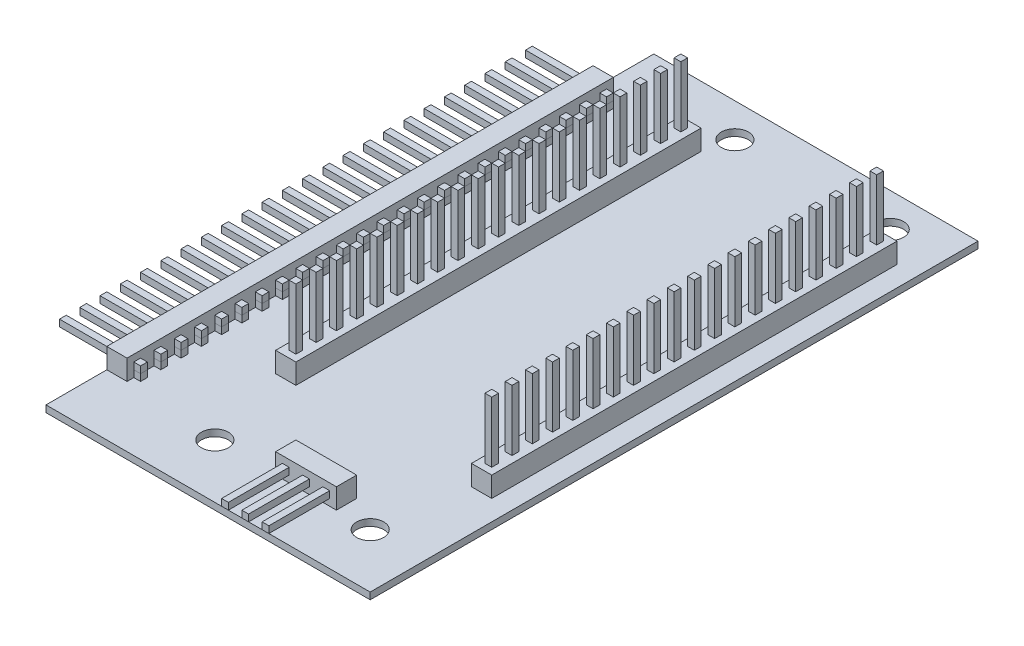
from build123d import *

# Parameters (mm, degrees)
SKETCH1_W              = 38.1
SKETCH1_H              = 71.4375
BOSS_EXTRUDE1_DEPTH    = 0.79375
SKETCH2_W              = 0.79375
SKETCH2_H              = 0.79375
BOSS_EXTRUDE2_DEPTH    = 0.79375
BOSS_EXTRUDE2_2_DEPTH  = 0.79375
BOSS_EXTRUDE2_3_DEPTH  = 0.79375
BOSS_EXTRUDE2_4_DEPTH  = 0.79375
BOSS_EXTRUDE2_5_DEPTH  = 0.79375
BOSS_EXTRUDE2_6_DEPTH  = 0.79375
BOSS_EXTRUDE2_7_DEPTH  = 0.79375
BOSS_EXTRUDE2_8_DEPTH  = 0.79375
BOSS_EXTRUDE2_9_DEPTH  = 0.79375
BOSS_EXTRUDE2_10_DEPTH = 0.79375
BOSS_EXTRUDE2_11_DEPTH = 0.79375
BOSS_EXTRUDE2_12_DEPTH = 0.79375
BOSS_EXTRUDE2_13_DEPTH = 0.79375
BOSS_EXTRUDE2_14_DEPTH = 0.79375
BOSS_EXTRUDE2_15_DEPTH = 0.79375
BOSS_EXTRUDE2_16_DEPTH = 0.79375
BOSS_EXTRUDE2_17_DEPTH = 0.79375
BOSS_EXTRUDE2_18_DEPTH = 0.79375
BOSS_EXTRUDE2_19_DEPTH = 0.79375
BOSS_EXTRUDE2_20_DEPTH = 0.79375
BOSS_EXTRUDE2_21_DEPTH = 0.79375
BOSS_EXTRUDE2_22_DEPTH = 0.79375
BOSS_EXTRUDE2_23_DEPTH = 0.79375
BOSS_EXTRUDE2_24_DEPTH = 0.79375
BOSS_EXTRUDE3_START    = 0.79375
SKETCH2_3_W            = 9.525
SKETCH2_3_H            = 0.79375
BOSS_EXTRUDE3_DEPTH    = 0.79375
BOSS_EXTRUDE3_2_DEPTH  = 0.79375
BOSS_EXTRUDE3_3_DEPTH  = 0.79375
BOSS_EXTRUDE3_4_DEPTH  = 0.79375
BOSS_EXTRUDE3_5_DEPTH  = 0.79375
BOSS_EXTRUDE3_6_DEPTH  = 0.79375
BOSS_EXTRUDE3_7_DEPTH  = 0.79375
BOSS_EXTRUDE3_8_DEPTH  = 0.79375
BOSS_EXTRUDE3_9_DEPTH  = 0.79375
BOSS_EXTRUDE3_10_DEPTH = 0.79375
BOSS_EXTRUDE3_11_DEPTH = 0.79375
BOSS_EXTRUDE3_12_DEPTH = 0.79375
BOSS_EXTRUDE3_13_DEPTH = 0.79375
BOSS_EXTRUDE3_14_DEPTH = 0.79375
BOSS_EXTRUDE3_15_DEPTH = 0.79375
BOSS_EXTRUDE3_16_DEPTH = 0.79375
BOSS_EXTRUDE3_17_DEPTH = 0.79375
BOSS_EXTRUDE3_18_DEPTH = 0.79375
BOSS_EXTRUDE3_19_DEPTH = 0.79375
BOSS_EXTRUDE3_20_DEPTH = 0.79375
BOSS_EXTRUDE3_21_DEPTH = 0.79375
BOSS_EXTRUDE3_22_DEPTH = 0.79375
BOSS_EXTRUDE3_23_DEPTH = 0.79375
BOSS_EXTRUDE3_24_DEPTH = 0.79375
SKETCH3_W              = 2.38125
SKETCH3_H              = 57.15
BOSS_EXTRUDE4_DEPTH    = 2.38125
SKETCH4_W              = 0.79375
SKETCH4_H              = 0.79375
BOSS_EXTRUDE5_DEPTH    = 9.525
BOSS_EXTRUDE5_2_DEPTH  = 9.525
BOSS_EXTRUDE5_3_DEPTH  = 9.525
BOSS_EXTRUDE5_4_DEPTH  = 9.525
BOSS_EXTRUDE5_5_DEPTH  = 9.525
BOSS_EXTRUDE5_6_DEPTH  = 9.525
BOSS_EXTRUDE5_7_DEPTH  = 9.525
BOSS_EXTRUDE5_8_DEPTH  = 9.525
BOSS_EXTRUDE5_9_DEPTH  = 9.525
BOSS_EXTRUDE5_10_DEPTH = 9.525
BOSS_EXTRUDE5_11_DEPTH = 9.525
BOSS_EXTRUDE5_12_DEPTH = 9.525
BOSS_EXTRUDE5_13_DEPTH = 9.525
BOSS_EXTRUDE5_14_DEPTH = 9.525
BOSS_EXTRUDE5_15_DEPTH = 9.525
BOSS_EXTRUDE5_16_DEPTH = 9.525
BOSS_EXTRUDE5_17_DEPTH = 9.525
BOSS_EXTRUDE5_18_DEPTH = 9.525
BOSS_EXTRUDE5_19_DEPTH = 9.525
BOSS_EXTRUDE5_20_DEPTH = 9.525
BOSS_EXTRUDE5_21_DEPTH = 9.525
BOSS_EXTRUDE5_22_DEPTH = 9.525
BOSS_EXTRUDE5_23_DEPTH = 9.525
BOSS_EXTRUDE5_24_DEPTH = 9.525
BOSS_EXTRUDE5_25_DEPTH = 9.525
BOSS_EXTRUDE5_26_DEPTH = 9.525
BOSS_EXTRUDE5_27_DEPTH = 9.525
BOSS_EXTRUDE5_28_DEPTH = 9.525
BOSS_EXTRUDE5_29_DEPTH = 9.525
BOSS_EXTRUDE5_30_DEPTH = 9.525
BOSS_EXTRUDE5_31_DEPTH = 9.525
BOSS_EXTRUDE5_32_DEPTH = 9.525
BOSS_EXTRUDE5_33_DEPTH = 9.525
BOSS_EXTRUDE5_34_DEPTH = 9.525
BOSS_EXTRUDE5_35_DEPTH = 9.525
BOSS_EXTRUDE5_36_DEPTH = 9.525
BOSS_EXTRUDE5_37_DEPTH = 9.525
BOSS_EXTRUDE5_38_DEPTH = 9.525
BOSS_EXTRUDE5_39_DEPTH = 9.525
BOSS_EXTRUDE5_40_DEPTH = 9.525
SKETCH5_W              = 2.38125
SKETCH5_H              = 47.625
BOSS_EXTRUDE6_DEPTH    = 2.38125
SKETCH6_W              = 0.79375
SKETCH6_H              = 0.79375
BOSS_EXTRUDE7_DEPTH    = 0.79375
BOSS_EXTRUDE8_START    = 0.79375
SKETCH6_3_W            = 0.79375
SKETCH6_3_H            = 10.31875
BOSS_EXTRUDE8_DEPTH    = 0.79375
BOSS_EXTRUDE8_2_DEPTH  = 0.79375
BOSS_EXTRUDE8_3_DEPTH  = 0.79375
SKETCH7_W              = 7.14375
SKETCH7_H              = 2.38125
BOSS_EXTRUDE9_DEPTH    = 2.38125
SKETCH8_R              = 1.5875
CUT_EXTRUDE1_DEPTH     = 46.486792383


with BuildPart() as part:
    # Sketch1 → Boss-Extrude1 (new body)
    with BuildSketch(Plane(origin=(0, 0, 0), x_dir=(1, 0, 0), z_dir=(0, 1, 0))):
        Rectangle(SKETCH1_W, SKETCH1_H)
    extrude(amount=BOSS_EXTRUDE1_DEPTH)

    # Sketch5 → Boss-Extrude6 (add)
    with BuildSketch(Plane(origin=(0, 0.79375, 0), x_dir=(1, 0, 0), z_dir=(0, 1, 0))):
        with Locations((-7.540625, 4.7625)):
            Rectangle(SKETCH5_W, SKETCH5_H)
        with Locations((15.478125, 4.7625)):
            Rectangle(SKETCH5_W, SKETCH5_H)
    extrude(amount=BOSS_EXTRUDE6_DEPTH)

    # Sketch6 → Boss-Extrude7 (add)
    with BuildSketch(Plane(origin=(0, 0.79375, 0), x_dir=(1, 0, 0), z_dir=(0, 1, 0))):
        with Locations((2.778125, -26.590625)):
            Rectangle(SKETCH6_W, SKETCH6_H)
        with Locations((5.159375, -26.590625)):
            Rectangle(SKETCH6_W, SKETCH6_H)
        with Locations((7.540625, -26.590625)):
            Rectangle(SKETCH6_W, SKETCH6_H)
    extrude(amount=BOSS_EXTRUDE7_DEPTH)

    # Sketch7 → Boss-Extrude9 (add)
    with BuildSketch(Plane(origin=(0, 0.79375, 0), x_dir=(1, 0, 0), z_dir=(0, 1, 0))):
        with Locations((5.159375, -28.178125)):
            Rectangle(SKETCH7_W, SKETCH7_H)
    extrude(amount=BOSS_EXTRUDE9_DEPTH)

    # Sketch8 → Cut-Extrude1 (cut, through all)
    with BuildSketch(Plane(origin=(0, 0.79375, 0), x_dir=(1, 0, 0), z_dir=(0, 1, 0))):
        with Locations((-5.55625, 31.75)):
            Circle(SKETCH8_R)
        with Locations((12.7, 31.75)):
            Circle(SKETCH8_R)
        with Locations((-5.55625, -29.36875)):
            Circle(SKETCH8_R)
        with Locations((12.7, -29.36875)):
            Circle(SKETCH8_R)
    extrude(amount=-CUT_EXTRUDE1_DEPTH, mode=Mode.SUBTRACT)


with BuildPart() as body_2:
    # Sketch2 → Boss-Extrude2 (new body)
    with BuildSketch(Plane(origin=(0, 0.79375, 0), x_dir=(1, 0, 0), z_dir=(0, 1, 0))):
        with Locations((-16.271875, 1.190625)):
            Rectangle(SKETCH2_W, SKETCH2_H)
    extrude(amount=BOSS_EXTRUDE2_DEPTH)


with BuildPart() as body_3:
    # Sketch2 → Boss-Extrude2 2 (new body)
    with BuildSketch(Plane(origin=(0, 0.79375, 0), x_dir=(1, 0, 0), z_dir=(0, 1, 0))):
        with Locations((-16.271875, 3.571875)):
            Rectangle(SKETCH2_W, SKETCH2_H)
    extrude(amount=BOSS_EXTRUDE2_2_DEPTH)


with BuildPart() as body_4:
    # Sketch2 → Boss-Extrude2 3 (new body)
    with BuildSketch(Plane(origin=(0, 0.79375, 0), x_dir=(1, 0, 0), z_dir=(0, 1, 0))):
        with Locations((-16.271875, 8.334375)):
            Rectangle(SKETCH2_W, SKETCH2_H)
    extrude(amount=BOSS_EXTRUDE2_3_DEPTH)


with BuildPart() as body_5:
    # Sketch2 → Boss-Extrude2 4 (new body)
    with BuildSketch(Plane(origin=(0, 0.79375, 0), x_dir=(1, 0, 0), z_dir=(0, 1, 0))):
        with Locations((-16.271875, 5.953125)):
            Rectangle(SKETCH2_W, SKETCH2_H)
    extrude(amount=BOSS_EXTRUDE2_4_DEPTH)


with BuildPart() as body_6:
    # Sketch2 → Boss-Extrude2 5 (new body)
    with BuildSketch(Plane(origin=(0, 0.79375, 0), x_dir=(1, 0, 0), z_dir=(0, 1, 0))):
        with Locations((-16.271875, 10.715625)):
            Rectangle(SKETCH2_W, SKETCH2_H)
    extrude(amount=BOSS_EXTRUDE2_5_DEPTH)


with BuildPart() as body_7:
    # Sketch2 → Boss-Extrude2 6 (new body)
    with BuildSketch(Plane(origin=(0, 0.79375, 0), x_dir=(1, 0, 0), z_dir=(0, 1, 0))):
        with Locations((-16.271875, 13.096875)):
            Rectangle(SKETCH2_W, SKETCH2_H)
    extrude(amount=BOSS_EXTRUDE2_6_DEPTH)


with BuildPart() as body_8:
    # Sketch2 → Boss-Extrude2 7 (new body)
    with BuildSketch(Plane(origin=(0, 0.79375, 0), x_dir=(1, 0, 0), z_dir=(0, 1, 0))):
        with Locations((-16.271875, 15.478125)):
            Rectangle(SKETCH2_W, SKETCH2_H)
    extrude(amount=BOSS_EXTRUDE2_7_DEPTH)


with BuildPart() as body_9:
    # Sketch2 → Boss-Extrude2 8 (new body)
    with BuildSketch(Plane(origin=(0, 0.79375, 0), x_dir=(1, 0, 0), z_dir=(0, 1, 0))):
        with Locations((-16.271875, 17.859375)):
            Rectangle(SKETCH2_W, SKETCH2_H)
    extrude(amount=BOSS_EXTRUDE2_8_DEPTH)


with BuildPart() as body_10:
    # Sketch2 → Boss-Extrude2 9 (new body)
    with BuildSketch(Plane(origin=(0, 0.79375, 0), x_dir=(1, 0, 0), z_dir=(0, 1, 0))):
        with Locations((-16.271875, 20.240625)):
            Rectangle(SKETCH2_W, SKETCH2_H)
    extrude(amount=BOSS_EXTRUDE2_9_DEPTH)


with BuildPart() as body_11:
    # Sketch2 → Boss-Extrude2 10 (new body)
    with BuildSketch(Plane(origin=(0, 0.79375, 0), x_dir=(1, 0, 0), z_dir=(0, 1, 0))):
        with Locations((-16.271875, 22.621875)):
            Rectangle(SKETCH2_W, SKETCH2_H)
    extrude(amount=BOSS_EXTRUDE2_10_DEPTH)


with BuildPart() as body_12:
    # Sketch2 → Boss-Extrude2 11 (new body)
    with BuildSketch(Plane(origin=(0, 0.79375, 0), x_dir=(1, 0, 0), z_dir=(0, 1, 0))):
        with Locations((-16.271875, 25.003125)):
            Rectangle(SKETCH2_W, SKETCH2_H)
    extrude(amount=BOSS_EXTRUDE2_11_DEPTH)


with BuildPart() as body_13:
    # Sketch2 → Boss-Extrude2 12 (new body)
    with BuildSketch(Plane(origin=(0, 0.79375, 0), x_dir=(1, 0, 0), z_dir=(0, 1, 0))):
        with Locations((-16.271875, 27.384375)):
            Rectangle(SKETCH2_W, SKETCH2_H)
    extrude(amount=BOSS_EXTRUDE2_12_DEPTH)


with BuildPart() as body_14:
    # Sketch2 → Boss-Extrude2 13 (new body)
    with BuildSketch(Plane(origin=(0, 0.79375, 0), x_dir=(1, 0, 0), z_dir=(0, 1, 0))):
        with Locations((-16.271875, -27.384375)):
            Rectangle(SKETCH2_W, SKETCH2_H)
    extrude(amount=BOSS_EXTRUDE2_13_DEPTH)


with BuildPart() as body_15:
    # Sketch2 → Boss-Extrude2 14 (new body)
    with BuildSketch(Plane(origin=(0, 0.79375, 0), x_dir=(1, 0, 0), z_dir=(0, 1, 0))):
        with Locations((-16.271875, -25.003125)):
            Rectangle(SKETCH2_W, SKETCH2_H)
    extrude(amount=BOSS_EXTRUDE2_14_DEPTH)


with BuildPart() as body_16:
    # Sketch2 → Boss-Extrude2 15 (new body)
    with BuildSketch(Plane(origin=(0, 0.79375, 0), x_dir=(1, 0, 0), z_dir=(0, 1, 0))):
        with Locations((-16.271875, -22.621875)):
            Rectangle(SKETCH2_W, SKETCH2_H)
    extrude(amount=BOSS_EXTRUDE2_15_DEPTH)


with BuildPart() as body_17:
    # Sketch2 → Boss-Extrude2 16 (new body)
    with BuildSketch(Plane(origin=(0, 0.79375, 0), x_dir=(1, 0, 0), z_dir=(0, 1, 0))):
        with Locations((-16.271875, -17.859375)):
            Rectangle(SKETCH2_W, SKETCH2_H)
    extrude(amount=BOSS_EXTRUDE2_16_DEPTH)


with BuildPart() as body_18:
    # Sketch2 → Boss-Extrude2 17 (new body)
    with BuildSketch(Plane(origin=(0, 0.79375, 0), x_dir=(1, 0, 0), z_dir=(0, 1, 0))):
        with Locations((-16.271875, -20.240625)):
            Rectangle(SKETCH2_W, SKETCH2_H)
    extrude(amount=BOSS_EXTRUDE2_17_DEPTH)


with BuildPart() as body_19:
    # Sketch2 → Boss-Extrude2 18 (new body)
    with BuildSketch(Plane(origin=(0, 0.79375, 0), x_dir=(1, 0, 0), z_dir=(0, 1, 0))):
        with Locations((-16.271875, -15.478125)):
            Rectangle(SKETCH2_W, SKETCH2_H)
    extrude(amount=BOSS_EXTRUDE2_18_DEPTH)


with BuildPart() as body_20:
    # Sketch2 → Boss-Extrude2 19 (new body)
    with BuildSketch(Plane(origin=(0, 0.79375, 0), x_dir=(1, 0, 0), z_dir=(0, 1, 0))):
        with Locations((-16.271875, -13.096875)):
            Rectangle(SKETCH2_W, SKETCH2_H)
    extrude(amount=BOSS_EXTRUDE2_19_DEPTH)


with BuildPart() as body_21:
    # Sketch2 → Boss-Extrude2 20 (new body)
    with BuildSketch(Plane(origin=(0, 0.79375, 0), x_dir=(1, 0, 0), z_dir=(0, 1, 0))):
        with Locations((-16.271875, -10.715625)):
            Rectangle(SKETCH2_W, SKETCH2_H)
    extrude(amount=BOSS_EXTRUDE2_20_DEPTH)


with BuildPart() as body_22:
    # Sketch2 → Boss-Extrude2 21 (new body)
    with BuildSketch(Plane(origin=(0, 0.79375, 0), x_dir=(1, 0, 0), z_dir=(0, 1, 0))):
        with Locations((-16.271875, -5.953125)):
            Rectangle(SKETCH2_W, SKETCH2_H)
    extrude(amount=BOSS_EXTRUDE2_21_DEPTH)


with BuildPart() as body_23:
    # Sketch2 → Boss-Extrude2 22 (new body)
    with BuildSketch(Plane(origin=(0, 0.79375, 0), x_dir=(1, 0, 0), z_dir=(0, 1, 0))):
        with Locations((-16.271875, -8.334375)):
            Rectangle(SKETCH2_W, SKETCH2_H)
    extrude(amount=BOSS_EXTRUDE2_22_DEPTH)


with BuildPart() as body_24:
    # Sketch2 → Boss-Extrude2 23 (new body)
    with BuildSketch(Plane(origin=(0, 0.79375, 0), x_dir=(1, 0, 0), z_dir=(0, 1, 0))):
        with Locations((-16.271875, -3.571875)):
            Rectangle(SKETCH2_W, SKETCH2_H)
    extrude(amount=BOSS_EXTRUDE2_23_DEPTH)


with BuildPart() as body_25:
    # Sketch2 → Boss-Extrude2 24 (new body)
    with BuildSketch(Plane(origin=(0, 0.79375, 0), x_dir=(1, 0, 0), z_dir=(0, 1, 0))):
        with Locations((-16.271875, -1.190625)):
            Rectangle(SKETCH2_W, SKETCH2_H)
    extrude(amount=BOSS_EXTRUDE2_24_DEPTH)


with BuildPart() as body_26:
    # Sketch2_3 → Boss-Extrude3 (new body)
    with BuildSketch(Plane(origin=(0, 0.79375, 0), x_dir=(1, 0, 0), z_dir=(0, 1, 0)).offset(BOSS_EXTRUDE3_START)):
        with Locations((-20.6375, 1.190625)):
            Rectangle(SKETCH2_3_W, SKETCH2_3_H)
    extrude(amount=BOSS_EXTRUDE3_DEPTH)


with BuildPart() as body_27:
    # Sketch2_3 → Boss-Extrude3 2 (new body)
    with BuildSketch(Plane(origin=(0, 0.79375, 0), x_dir=(1, 0, 0), z_dir=(0, 1, 0)).offset(BOSS_EXTRUDE3_START)):
        with Locations((-20.6375, 3.571875)):
            Rectangle(SKETCH2_3_W, SKETCH2_3_H)
    extrude(amount=BOSS_EXTRUDE3_2_DEPTH)


with BuildPart() as body_28:
    # Sketch2_3 → Boss-Extrude3 3 (new body)
    with BuildSketch(Plane(origin=(0, 0.79375, 0), x_dir=(1, 0, 0), z_dir=(0, 1, 0)).offset(BOSS_EXTRUDE3_START)):
        with Locations((-20.6375, 8.334375)):
            Rectangle(SKETCH2_3_W, SKETCH2_3_H)
    extrude(amount=BOSS_EXTRUDE3_3_DEPTH)


with BuildPart() as body_29:
    # Sketch2_3 → Boss-Extrude3 4 (new body)
    with BuildSketch(Plane(origin=(0, 0.79375, 0), x_dir=(1, 0, 0), z_dir=(0, 1, 0)).offset(BOSS_EXTRUDE3_START)):
        with Locations((-20.6375, 5.953125)):
            Rectangle(SKETCH2_3_W, SKETCH2_3_H)
    extrude(amount=BOSS_EXTRUDE3_4_DEPTH)


with BuildPart() as body_30:
    # Sketch2_3 → Boss-Extrude3 5 (new body)
    with BuildSketch(Plane(origin=(0, 0.79375, 0), x_dir=(1, 0, 0), z_dir=(0, 1, 0)).offset(BOSS_EXTRUDE3_START)):
        with Locations((-20.6375, 10.715625)):
            Rectangle(SKETCH2_3_W, SKETCH2_3_H)
    extrude(amount=BOSS_EXTRUDE3_5_DEPTH)


with BuildPart() as body_31:
    # Sketch2_3 → Boss-Extrude3 6 (new body)
    with BuildSketch(Plane(origin=(0, 0.79375, 0), x_dir=(1, 0, 0), z_dir=(0, 1, 0)).offset(BOSS_EXTRUDE3_START)):
        with Locations((-20.6375, 13.096875)):
            Rectangle(SKETCH2_3_W, SKETCH2_3_H)
    extrude(amount=BOSS_EXTRUDE3_6_DEPTH)


with BuildPart() as body_32:
    # Sketch2_3 → Boss-Extrude3 7 (new body)
    with BuildSketch(Plane(origin=(0, 0.79375, 0), x_dir=(1, 0, 0), z_dir=(0, 1, 0)).offset(BOSS_EXTRUDE3_START)):
        with Locations((-20.6375, 15.478125)):
            Rectangle(SKETCH2_3_W, SKETCH2_3_H)
    extrude(amount=BOSS_EXTRUDE3_7_DEPTH)


with BuildPart() as body_33:
    # Sketch2_3 → Boss-Extrude3 8 (new body)
    with BuildSketch(Plane(origin=(0, 0.79375, 0), x_dir=(1, 0, 0), z_dir=(0, 1, 0)).offset(BOSS_EXTRUDE3_START)):
        with Locations((-20.6375, 17.859375)):
            Rectangle(SKETCH2_3_W, SKETCH2_3_H)
    extrude(amount=BOSS_EXTRUDE3_8_DEPTH)


with BuildPart() as body_34:
    # Sketch2_3 → Boss-Extrude3 9 (new body)
    with BuildSketch(Plane(origin=(0, 0.79375, 0), x_dir=(1, 0, 0), z_dir=(0, 1, 0)).offset(BOSS_EXTRUDE3_START)):
        with Locations((-20.6375, 20.240625)):
            Rectangle(SKETCH2_3_W, SKETCH2_3_H)
    extrude(amount=BOSS_EXTRUDE3_9_DEPTH)


with BuildPart() as body_35:
    # Sketch2_3 → Boss-Extrude3 10 (new body)
    with BuildSketch(Plane(origin=(0, 0.79375, 0), x_dir=(1, 0, 0), z_dir=(0, 1, 0)).offset(BOSS_EXTRUDE3_START)):
        with Locations((-20.6375, 22.621875)):
            Rectangle(SKETCH2_3_W, SKETCH2_3_H)
    extrude(amount=BOSS_EXTRUDE3_10_DEPTH)


with BuildPart() as body_36:
    # Sketch2_3 → Boss-Extrude3 11 (new body)
    with BuildSketch(Plane(origin=(0, 0.79375, 0), x_dir=(1, 0, 0), z_dir=(0, 1, 0)).offset(BOSS_EXTRUDE3_START)):
        with Locations((-20.6375, 25.003125)):
            Rectangle(SKETCH2_3_W, SKETCH2_3_H)
    extrude(amount=BOSS_EXTRUDE3_11_DEPTH)


with BuildPart() as body_37:
    # Sketch2_3 → Boss-Extrude3 12 (new body)
    with BuildSketch(Plane(origin=(0, 0.79375, 0), x_dir=(1, 0, 0), z_dir=(0, 1, 0)).offset(BOSS_EXTRUDE3_START)):
        with Locations((-20.6375, 27.384375)):
            Rectangle(SKETCH2_3_W, SKETCH2_3_H)
    extrude(amount=BOSS_EXTRUDE3_12_DEPTH)


with BuildPart() as body_38:
    # Sketch2_3 → Boss-Extrude3 13 (new body)
    with BuildSketch(Plane(origin=(0, 0.79375, 0), x_dir=(1, 0, 0), z_dir=(0, 1, 0)).offset(BOSS_EXTRUDE3_START)):
        with Locations((-20.6375, -27.384375)):
            Rectangle(SKETCH2_3_W, SKETCH2_3_H)
    extrude(amount=BOSS_EXTRUDE3_13_DEPTH)


with BuildPart() as body_39:
    # Sketch2_3 → Boss-Extrude3 14 (new body)
    with BuildSketch(Plane(origin=(0, 0.79375, 0), x_dir=(1, 0, 0), z_dir=(0, 1, 0)).offset(BOSS_EXTRUDE3_START)):
        with Locations((-20.6375, -25.003125)):
            Rectangle(SKETCH2_3_W, SKETCH2_3_H)
    extrude(amount=BOSS_EXTRUDE3_14_DEPTH)


with BuildPart() as body_40:
    # Sketch2_3 → Boss-Extrude3 15 (new body)
    with BuildSketch(Plane(origin=(0, 0.79375, 0), x_dir=(1, 0, 0), z_dir=(0, 1, 0)).offset(BOSS_EXTRUDE3_START)):
        with Locations((-20.6375, -22.621875)):
            Rectangle(SKETCH2_3_W, SKETCH2_3_H)
    extrude(amount=BOSS_EXTRUDE3_15_DEPTH)


with BuildPart() as body_41:
    # Sketch2_3 → Boss-Extrude3 16 (new body)
    with BuildSketch(Plane(origin=(0, 0.79375, 0), x_dir=(1, 0, 0), z_dir=(0, 1, 0)).offset(BOSS_EXTRUDE3_START)):
        with Locations((-20.6375, -20.240625)):
            Rectangle(SKETCH2_3_W, SKETCH2_3_H)
    extrude(amount=BOSS_EXTRUDE3_16_DEPTH)


with BuildPart() as body_42:
    # Sketch2_3 → Boss-Extrude3 17 (new body)
    with BuildSketch(Plane(origin=(0, 0.79375, 0), x_dir=(1, 0, 0), z_dir=(0, 1, 0)).offset(BOSS_EXTRUDE3_START)):
        with Locations((-20.6375, -17.859375)):
            Rectangle(SKETCH2_3_W, SKETCH2_3_H)
    extrude(amount=BOSS_EXTRUDE3_17_DEPTH)


with BuildPart() as body_43:
    # Sketch2_3 → Boss-Extrude3 18 (new body)
    with BuildSketch(Plane(origin=(0, 0.79375, 0), x_dir=(1, 0, 0), z_dir=(0, 1, 0)).offset(BOSS_EXTRUDE3_START)):
        with Locations((-20.6375, -15.478125)):
            Rectangle(SKETCH2_3_W, SKETCH2_3_H)
    extrude(amount=BOSS_EXTRUDE3_18_DEPTH)


with BuildPart() as body_44:
    # Sketch2_3 → Boss-Extrude3 19 (new body)
    with BuildSketch(Plane(origin=(0, 0.79375, 0), x_dir=(1, 0, 0), z_dir=(0, 1, 0)).offset(BOSS_EXTRUDE3_START)):
        with Locations((-20.6375, -13.096875)):
            Rectangle(SKETCH2_3_W, SKETCH2_3_H)
    extrude(amount=BOSS_EXTRUDE3_19_DEPTH)


with BuildPart() as body_45:
    # Sketch2_3 → Boss-Extrude3 20 (new body)
    with BuildSketch(Plane(origin=(0, 0.79375, 0), x_dir=(1, 0, 0), z_dir=(0, 1, 0)).offset(BOSS_EXTRUDE3_START)):
        with Locations((-20.6375, -10.715625)):
            Rectangle(SKETCH2_3_W, SKETCH2_3_H)
    extrude(amount=BOSS_EXTRUDE3_20_DEPTH)


with BuildPart() as body_46:
    # Sketch2_3 → Boss-Extrude3 21 (new body)
    with BuildSketch(Plane(origin=(0, 0.79375, 0), x_dir=(1, 0, 0), z_dir=(0, 1, 0)).offset(BOSS_EXTRUDE3_START)):
        with Locations((-20.6375, -5.953125)):
            Rectangle(SKETCH2_3_W, SKETCH2_3_H)
    extrude(amount=BOSS_EXTRUDE3_21_DEPTH)


with BuildPart() as body_47:
    # Sketch2_3 → Boss-Extrude3 22 (new body)
    with BuildSketch(Plane(origin=(0, 0.79375, 0), x_dir=(1, 0, 0), z_dir=(0, 1, 0)).offset(BOSS_EXTRUDE3_START)):
        with Locations((-20.6375, -8.334375)):
            Rectangle(SKETCH2_3_W, SKETCH2_3_H)
    extrude(amount=BOSS_EXTRUDE3_22_DEPTH)


with BuildPart() as body_48:
    # Sketch2_3 → Boss-Extrude3 23 (new body)
    with BuildSketch(Plane(origin=(0, 0.79375, 0), x_dir=(1, 0, 0), z_dir=(0, 1, 0)).offset(BOSS_EXTRUDE3_START)):
        with Locations((-20.6375, -3.571875)):
            Rectangle(SKETCH2_3_W, SKETCH2_3_H)
    extrude(amount=BOSS_EXTRUDE3_23_DEPTH)


with BuildPart() as body_49:
    # Sketch2_3 → Boss-Extrude3 24 (new body)
    with BuildSketch(Plane(origin=(0, 0.79375, 0), x_dir=(1, 0, 0), z_dir=(0, 1, 0)).offset(BOSS_EXTRUDE3_START)):
        with Locations((-20.6375, -1.190625)):
            Rectangle(SKETCH2_3_W, SKETCH2_3_H)
    extrude(amount=BOSS_EXTRUDE3_24_DEPTH)


with BuildPart() as body_50:
    # Sketch3 → Boss-Extrude4 (new body)
    with BuildSketch(Plane(origin=(0, 0.79375, 0), x_dir=(1, 0, 0), z_dir=(0, 1, 0))):
        with Locations((-17.859375, 0)):
            Rectangle(SKETCH3_W, SKETCH3_H)
    extrude(amount=BOSS_EXTRUDE4_DEPTH)


with BuildPart() as body_51:
    # Sketch4 → Boss-Extrude5 (new body)
    with BuildSketch(Plane(origin=(0, 0.79375, 0), x_dir=(1, 0, 0), z_dir=(0, 1, 0))):
        with Locations((-7.540625, 25.003125)):
            Rectangle(SKETCH4_W, SKETCH4_H)
    extrude(amount=BOSS_EXTRUDE5_DEPTH)


with BuildPart() as body_52:
    # Sketch4 → Boss-Extrude5 2 (new body)
    with BuildSketch(Plane(origin=(0, 0.79375, 0), x_dir=(1, 0, 0), z_dir=(0, 1, 0))):
        with Locations((-7.540625, 22.621875)):
            Rectangle(SKETCH4_W, SKETCH4_H)
    extrude(amount=BOSS_EXTRUDE5_2_DEPTH)


with BuildPart() as body_53:
    # Sketch4 → Boss-Extrude5 3 (new body)
    with BuildSketch(Plane(origin=(0, 0.79375, 0), x_dir=(1, 0, 0), z_dir=(0, 1, 0))):
        with Locations((-7.540625, 20.240625)):
            Rectangle(SKETCH4_W, SKETCH4_H)
    extrude(amount=BOSS_EXTRUDE5_3_DEPTH)


with BuildPart() as body_54:
    # Sketch4 → Boss-Extrude5 4 (new body)
    with BuildSketch(Plane(origin=(0, 0.79375, 0), x_dir=(1, 0, 0), z_dir=(0, 1, 0))):
        with Locations((-7.540625, 17.859375)):
            Rectangle(SKETCH4_W, SKETCH4_H)
    extrude(amount=BOSS_EXTRUDE5_4_DEPTH)


with BuildPart() as body_55:
    # Sketch4 → Boss-Extrude5 5 (new body)
    with BuildSketch(Plane(origin=(0, 0.79375, 0), x_dir=(1, 0, 0), z_dir=(0, 1, 0))):
        with Locations((-7.540625, 15.478125)):
            Rectangle(SKETCH4_W, SKETCH4_H)
    extrude(amount=BOSS_EXTRUDE5_5_DEPTH)


with BuildPart() as body_56:
    # Sketch4 → Boss-Extrude5 6 (new body)
    with BuildSketch(Plane(origin=(0, 0.79375, 0), x_dir=(1, 0, 0), z_dir=(0, 1, 0))):
        with Locations((-7.540625, 13.096875)):
            Rectangle(SKETCH4_W, SKETCH4_H)
    extrude(amount=BOSS_EXTRUDE5_6_DEPTH)


with BuildPart() as body_57:
    # Sketch4 → Boss-Extrude5 7 (new body)
    with BuildSketch(Plane(origin=(0, 0.79375, 0), x_dir=(1, 0, 0), z_dir=(0, 1, 0))):
        with Locations((-7.540625, 10.715625)):
            Rectangle(SKETCH4_W, SKETCH4_H)
    extrude(amount=BOSS_EXTRUDE5_7_DEPTH)


with BuildPart() as body_58:
    # Sketch4 → Boss-Extrude5 8 (new body)
    with BuildSketch(Plane(origin=(0, 0.79375, 0), x_dir=(1, 0, 0), z_dir=(0, 1, 0))):
        with Locations((-7.540625, 8.334375)):
            Rectangle(SKETCH4_W, SKETCH4_H)
    extrude(amount=BOSS_EXTRUDE5_8_DEPTH)


with BuildPart() as body_59:
    # Sketch4 → Boss-Extrude5 9 (new body)
    with BuildSketch(Plane(origin=(0, 0.79375, 0), x_dir=(1, 0, 0), z_dir=(0, 1, 0))):
        with Locations((-7.540625, 27.384375)):
            Rectangle(SKETCH4_W, SKETCH4_H)
    extrude(amount=BOSS_EXTRUDE5_9_DEPTH)


with BuildPart() as body_60:
    # Sketch4 → Boss-Extrude5 10 (new body)
    with BuildSketch(Plane(origin=(0, 0.79375, 0), x_dir=(1, 0, 0), z_dir=(0, 1, 0))):
        with Locations((-7.540625, 5.953125)):
            Rectangle(SKETCH4_W, SKETCH4_H)
    extrude(amount=BOSS_EXTRUDE5_10_DEPTH)


with BuildPart() as body_61:
    # Sketch4 → Boss-Extrude5 11 (new body)
    with BuildSketch(Plane(origin=(0, 0.79375, 0), x_dir=(1, 0, 0), z_dir=(0, 1, 0))):
        with Locations((-7.540625, 3.571875)):
            Rectangle(SKETCH4_W, SKETCH4_H)
    extrude(amount=BOSS_EXTRUDE5_11_DEPTH)


with BuildPart() as body_62:
    # Sketch4 → Boss-Extrude5 12 (new body)
    with BuildSketch(Plane(origin=(0, 0.79375, 0), x_dir=(1, 0, 0), z_dir=(0, 1, 0))):
        with Locations((-7.540625, -17.859375)):
            Rectangle(SKETCH4_W, SKETCH4_H)
    extrude(amount=BOSS_EXTRUDE5_12_DEPTH)


with BuildPart() as body_63:
    # Sketch4 → Boss-Extrude5 13 (new body)
    with BuildSketch(Plane(origin=(0, 0.79375, 0), x_dir=(1, 0, 0), z_dir=(0, 1, 0))):
        with Locations((-7.540625, 1.190625)):
            Rectangle(SKETCH4_W, SKETCH4_H)
    extrude(amount=BOSS_EXTRUDE5_13_DEPTH)


with BuildPart() as body_64:
    # Sketch4 → Boss-Extrude5 14 (new body)
    with BuildSketch(Plane(origin=(0, 0.79375, 0), x_dir=(1, 0, 0), z_dir=(0, 1, 0))):
        with Locations((-7.540625, -1.190625)):
            Rectangle(SKETCH4_W, SKETCH4_H)
    extrude(amount=BOSS_EXTRUDE5_14_DEPTH)


with BuildPart() as body_65:
    # Sketch4 → Boss-Extrude5 15 (new body)
    with BuildSketch(Plane(origin=(0, 0.79375, 0), x_dir=(1, 0, 0), z_dir=(0, 1, 0))):
        with Locations((-7.540625, -3.571875)):
            Rectangle(SKETCH4_W, SKETCH4_H)
    extrude(amount=BOSS_EXTRUDE5_15_DEPTH)


with BuildPart() as body_66:
    # Sketch4 → Boss-Extrude5 16 (new body)
    with BuildSketch(Plane(origin=(0, 0.79375, 0), x_dir=(1, 0, 0), z_dir=(0, 1, 0))):
        with Locations((-7.540625, -5.953125)):
            Rectangle(SKETCH4_W, SKETCH4_H)
    extrude(amount=BOSS_EXTRUDE5_16_DEPTH)


with BuildPart() as body_67:
    # Sketch4 → Boss-Extrude5 17 (new body)
    with BuildSketch(Plane(origin=(0, 0.79375, 0), x_dir=(1, 0, 0), z_dir=(0, 1, 0))):
        with Locations((-7.540625, -8.334375)):
            Rectangle(SKETCH4_W, SKETCH4_H)
    extrude(amount=BOSS_EXTRUDE5_17_DEPTH)


with BuildPart() as body_68:
    # Sketch4 → Boss-Extrude5 18 (new body)
    with BuildSketch(Plane(origin=(0, 0.79375, 0), x_dir=(1, 0, 0), z_dir=(0, 1, 0))):
        with Locations((-7.540625, -10.715625)):
            Rectangle(SKETCH4_W, SKETCH4_H)
    extrude(amount=BOSS_EXTRUDE5_18_DEPTH)


with BuildPart() as body_69:
    # Sketch4 → Boss-Extrude5 19 (new body)
    with BuildSketch(Plane(origin=(0, 0.79375, 0), x_dir=(1, 0, 0), z_dir=(0, 1, 0))):
        with Locations((-7.540625, -13.096875)):
            Rectangle(SKETCH4_W, SKETCH4_H)
    extrude(amount=BOSS_EXTRUDE5_19_DEPTH)


with BuildPart() as body_70:
    # Sketch4 → Boss-Extrude5 20 (new body)
    with BuildSketch(Plane(origin=(0, 0.79375, 0), x_dir=(1, 0, 0), z_dir=(0, 1, 0))):
        with Locations((-7.540625, -15.478125)):
            Rectangle(SKETCH4_W, SKETCH4_H)
    extrude(amount=BOSS_EXTRUDE5_20_DEPTH)


with BuildPart() as body_71:
    # Sketch4 → Boss-Extrude5 21 (new body)
    with BuildSketch(Plane(origin=(0, 0.79375, 0), x_dir=(1, 0, 0), z_dir=(0, 1, 0))):
        with Locations((15.478125, -15.478125)):
            Rectangle(SKETCH4_W, SKETCH4_H)
    extrude(amount=BOSS_EXTRUDE5_21_DEPTH)


with BuildPart() as body_72:
    # Sketch4 → Boss-Extrude5 22 (new body)
    with BuildSketch(Plane(origin=(0, 0.79375, 0), x_dir=(1, 0, 0), z_dir=(0, 1, 0))):
        with Locations((15.478125, -13.096875)):
            Rectangle(SKETCH4_W, SKETCH4_H)
    extrude(amount=BOSS_EXTRUDE5_22_DEPTH)


with BuildPart() as body_73:
    # Sketch4 → Boss-Extrude5 23 (new body)
    with BuildSketch(Plane(origin=(0, 0.79375, 0), x_dir=(1, 0, 0), z_dir=(0, 1, 0))):
        with Locations((15.478125, -10.715625)):
            Rectangle(SKETCH4_W, SKETCH4_H)
    extrude(amount=BOSS_EXTRUDE5_23_DEPTH)


with BuildPart() as body_74:
    # Sketch4 → Boss-Extrude5 24 (new body)
    with BuildSketch(Plane(origin=(0, 0.79375, 0), x_dir=(1, 0, 0), z_dir=(0, 1, 0))):
        with Locations((15.478125, -8.334375)):
            Rectangle(SKETCH4_W, SKETCH4_H)
    extrude(amount=BOSS_EXTRUDE5_24_DEPTH)


with BuildPart() as body_75:
    # Sketch4 → Boss-Extrude5 25 (new body)
    with BuildSketch(Plane(origin=(0, 0.79375, 0), x_dir=(1, 0, 0), z_dir=(0, 1, 0))):
        with Locations((15.478125, -5.953125)):
            Rectangle(SKETCH4_W, SKETCH4_H)
    extrude(amount=BOSS_EXTRUDE5_25_DEPTH)


with BuildPart() as body_76:
    # Sketch4 → Boss-Extrude5 26 (new body)
    with BuildSketch(Plane(origin=(0, 0.79375, 0), x_dir=(1, 0, 0), z_dir=(0, 1, 0))):
        with Locations((15.478125, -3.571875)):
            Rectangle(SKETCH4_W, SKETCH4_H)
    extrude(amount=BOSS_EXTRUDE5_26_DEPTH)


with BuildPart() as body_77:
    # Sketch4 → Boss-Extrude5 27 (new body)
    with BuildSketch(Plane(origin=(0, 0.79375, 0), x_dir=(1, 0, 0), z_dir=(0, 1, 0))):
        with Locations((15.478125, -1.190625)):
            Rectangle(SKETCH4_W, SKETCH4_H)
    extrude(amount=BOSS_EXTRUDE5_27_DEPTH)


with BuildPart() as body_78:
    # Sketch4 → Boss-Extrude5 28 (new body)
    with BuildSketch(Plane(origin=(0, 0.79375, 0), x_dir=(1, 0, 0), z_dir=(0, 1, 0))):
        with Locations((15.478125, 1.190625)):
            Rectangle(SKETCH4_W, SKETCH4_H)
    extrude(amount=BOSS_EXTRUDE5_28_DEPTH)


with BuildPart() as body_79:
    # Sketch4 → Boss-Extrude5 29 (new body)
    with BuildSketch(Plane(origin=(0, 0.79375, 0), x_dir=(1, 0, 0), z_dir=(0, 1, 0))):
        with Locations((15.478125, -17.859375)):
            Rectangle(SKETCH4_W, SKETCH4_H)
    extrude(amount=BOSS_EXTRUDE5_29_DEPTH)


with BuildPart() as body_80:
    # Sketch4 → Boss-Extrude5 30 (new body)
    with BuildSketch(Plane(origin=(0, 0.79375, 0), x_dir=(1, 0, 0), z_dir=(0, 1, 0))):
        with Locations((15.478125, 3.571875)):
            Rectangle(SKETCH4_W, SKETCH4_H)
    extrude(amount=BOSS_EXTRUDE5_30_DEPTH)


with BuildPart() as body_81:
    # Sketch4 → Boss-Extrude5 31 (new body)
    with BuildSketch(Plane(origin=(0, 0.79375, 0), x_dir=(1, 0, 0), z_dir=(0, 1, 0))):
        with Locations((15.478125, 5.953125)):
            Rectangle(SKETCH4_W, SKETCH4_H)
    extrude(amount=BOSS_EXTRUDE5_31_DEPTH)


with BuildPart() as body_82:
    # Sketch4 → Boss-Extrude5 32 (new body)
    with BuildSketch(Plane(origin=(0, 0.79375, 0), x_dir=(1, 0, 0), z_dir=(0, 1, 0))):
        with Locations((15.478125, 27.384375)):
            Rectangle(SKETCH4_W, SKETCH4_H)
    extrude(amount=BOSS_EXTRUDE5_32_DEPTH)


with BuildPart() as body_83:
    # Sketch4 → Boss-Extrude5 33 (new body)
    with BuildSketch(Plane(origin=(0, 0.79375, 0), x_dir=(1, 0, 0), z_dir=(0, 1, 0))):
        with Locations((15.478125, 8.334375)):
            Rectangle(SKETCH4_W, SKETCH4_H)
    extrude(amount=BOSS_EXTRUDE5_33_DEPTH)


with BuildPart() as body_84:
    # Sketch4 → Boss-Extrude5 34 (new body)
    with BuildSketch(Plane(origin=(0, 0.79375, 0), x_dir=(1, 0, 0), z_dir=(0, 1, 0))):
        with Locations((15.478125, 10.715625)):
            Rectangle(SKETCH4_W, SKETCH4_H)
    extrude(amount=BOSS_EXTRUDE5_34_DEPTH)


with BuildPart() as body_85:
    # Sketch4 → Boss-Extrude5 35 (new body)
    with BuildSketch(Plane(origin=(0, 0.79375, 0), x_dir=(1, 0, 0), z_dir=(0, 1, 0))):
        with Locations((15.478125, 13.096875)):
            Rectangle(SKETCH4_W, SKETCH4_H)
    extrude(amount=BOSS_EXTRUDE5_35_DEPTH)


with BuildPart() as body_86:
    # Sketch4 → Boss-Extrude5 36 (new body)
    with BuildSketch(Plane(origin=(0, 0.79375, 0), x_dir=(1, 0, 0), z_dir=(0, 1, 0))):
        with Locations((15.478125, 15.478125)):
            Rectangle(SKETCH4_W, SKETCH4_H)
    extrude(amount=BOSS_EXTRUDE5_36_DEPTH)


with BuildPart() as body_87:
    # Sketch4 → Boss-Extrude5 37 (new body)
    with BuildSketch(Plane(origin=(0, 0.79375, 0), x_dir=(1, 0, 0), z_dir=(0, 1, 0))):
        with Locations((15.478125, 17.859375)):
            Rectangle(SKETCH4_W, SKETCH4_H)
    extrude(amount=BOSS_EXTRUDE5_37_DEPTH)


with BuildPart() as body_88:
    # Sketch4 → Boss-Extrude5 38 (new body)
    with BuildSketch(Plane(origin=(0, 0.79375, 0), x_dir=(1, 0, 0), z_dir=(0, 1, 0))):
        with Locations((15.478125, 20.240625)):
            Rectangle(SKETCH4_W, SKETCH4_H)
    extrude(amount=BOSS_EXTRUDE5_38_DEPTH)


with BuildPart() as body_89:
    # Sketch4 → Boss-Extrude5 39 (new body)
    with BuildSketch(Plane(origin=(0, 0.79375, 0), x_dir=(1, 0, 0), z_dir=(0, 1, 0))):
        with Locations((15.478125, 22.621875)):
            Rectangle(SKETCH4_W, SKETCH4_H)
    extrude(amount=BOSS_EXTRUDE5_39_DEPTH)


with BuildPart() as body_90:
    # Sketch4 → Boss-Extrude5 40 (new body)
    with BuildSketch(Plane(origin=(0, 0.79375, 0), x_dir=(1, 0, 0), z_dir=(0, 1, 0))):
        with Locations((15.478125, 25.003125)):
            Rectangle(SKETCH4_W, SKETCH4_H)
    extrude(amount=BOSS_EXTRUDE5_40_DEPTH)


with BuildPart() as body_91:
    # Sketch6_3 → Boss-Extrude8 (new body)
    with BuildSketch(Plane(origin=(0, 0.79375, 0), x_dir=(1, 0, 0), z_dir=(0, 1, 0)).offset(BOSS_EXTRUDE8_START)):
        with Locations((2.778125, -31.353125)):
            Rectangle(SKETCH6_3_W, SKETCH6_3_H)
    extrude(amount=BOSS_EXTRUDE8_DEPTH)


with BuildPart() as body_92:
    # Sketch6_3 → Boss-Extrude8 2 (new body)
    with BuildSketch(Plane(origin=(0, 0.79375, 0), x_dir=(1, 0, 0), z_dir=(0, 1, 0)).offset(BOSS_EXTRUDE8_START)):
        with Locations((5.159375, -31.353125)):
            Rectangle(SKETCH6_3_W, SKETCH6_3_H)
    extrude(amount=BOSS_EXTRUDE8_2_DEPTH)


with BuildPart() as body_93:
    # Sketch6_3 → Boss-Extrude8 3 (new body)
    with BuildSketch(Plane(origin=(0, 0.79375, 0), x_dir=(1, 0, 0), z_dir=(0, 1, 0)).offset(BOSS_EXTRUDE8_START)):
        with Locations((7.540625, -31.353125)):
            Rectangle(SKETCH6_3_W, SKETCH6_3_H)
    extrude(amount=BOSS_EXTRUDE8_3_DEPTH)


solid = Compound([part.part, body_2.part, body_3.part, body_4.part, body_5.part, body_6.part, body_7.part, body_8.part, body_9.part, body_10.part, body_11.part, body_12.part, body_13.part, body_14.part, body_15.part, body_16.part, body_17.part, body_18.part, body_19.part, body_20.part, body_21.part, body_22.part, body_23.part, body_24.part, body_25.part, body_26.part, body_27.part, body_28.part, body_29.part, body_30.part, body_31.part, body_32.part, body_33.part, body_34.part, body_35.part, body_36.part, body_37.part, body_38.part, body_39.part, body_40.part, body_41.part, body_42.part, body_43.part, body_44.part, body_45.part, body_46.part, body_47.part, body_48.part, body_49.part, body_50.part, body_51.part, body_52.part, body_53.part, body_54.part, body_55.part, body_56.part, body_57.part, body_58.part, body_59.part, body_60.part, body_61.part, body_62.part, body_63.part, body_64.part, body_65.part, body_66.part, body_67.part, body_68.part, body_69.part, body_70.part, body_71.part, body_72.part, body_73.part, body_74.part, body_75.part, body_76.part, body_77.part, body_78.part, body_79.part, body_80.part, body_81.part, body_82.part, body_83.part, body_84.part, body_85.part, body_86.part, body_87.part, body_88.part, body_89.part, body_90.part, body_91.part, body_92.part, body_93.part])
